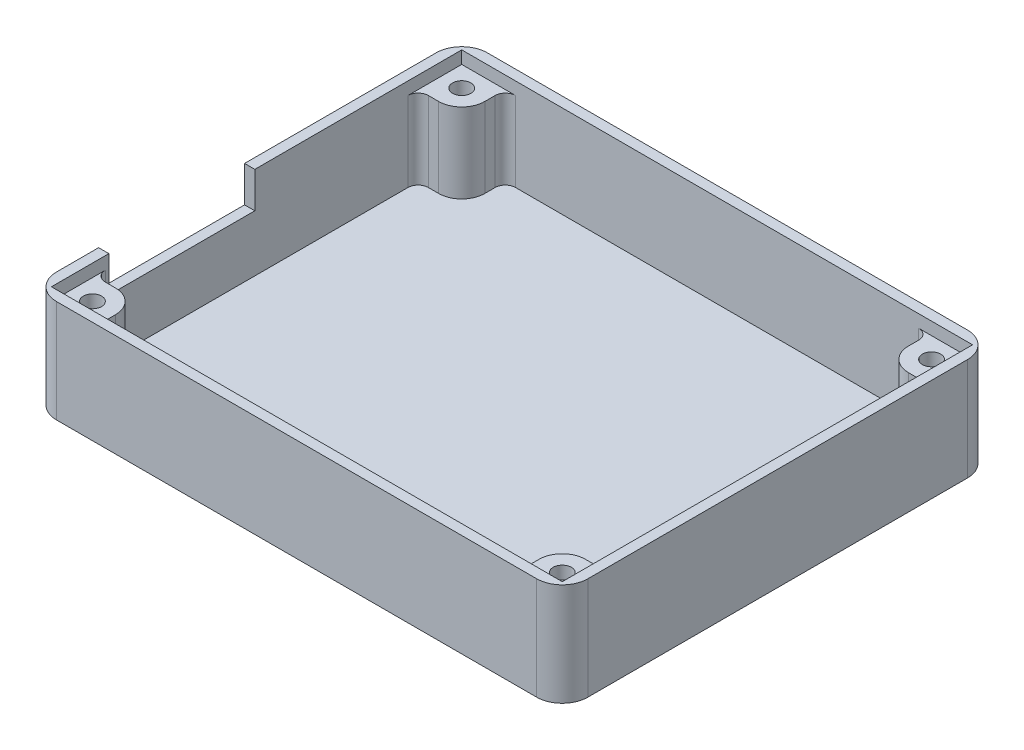
from build123d import *

# Parameters (mm, degrees)
SKETCH5_W             = 65.786
SKETCH5_H             = 53.34
BOSS_EXTRUDE1_DEPTH   = 12.7
CUT_EXTRUDE1_DEPTH    = 11.43
FILLET1_R             = 3.175
SKETCH8_W             = 63.246
SKETCH8_H             = 50.8
CUT_EXTRUDE2_DEPTH    = 1.5621
SKETCH9_W             = 15.301638829
SKETCH9_H             = 18.07026672
CUT_EXTRUDE3_DEPTH    = 4.445
BODY_MOVE_COPY1_ANGLE = 180


with BuildPart() as part:
    # Sketch5 → Boss-Extrude1 (new body)
    with BuildSketch(Plane(origin=(0, 0, 0), x_dir=(1, 0, 0), z_dir=(0, 1, 0))):
        with Locations((-7.078072202, 8.960606498)):
            Rectangle(SKETCH5_W, SKETCH5_H)
    extrude(amount=BOSS_EXTRUDE1_DEPTH)

    # Sketch7 → Cut-Extrude1 (cut)
    with BuildSketch(Plane.XZ):
        with BuildLine():
            Line((-32.033572202, -34.360606498), (17.877427798, -34.360606498))
            ThreePointArc((17.877427798, -34.360606498), (18.77545341, -33.98863211), (19.147427798, -33.090606498))
            Line((19.147427798, -33.090606498), (19.147427798, -31.820606498))
            ThreePointArc((19.147427798, -31.820606498), (19.984370171, -29.800048871), (22.004927798, -28.963106498))
            Line((22.004927798, -28.963106498), (23.274927798, -28.963106498))
            ThreePointArc((23.274927798, -28.963106498), (24.17295341, -28.59113211), (24.544927798, -27.693106498))
            Line((24.544927798, -27.693106498), (24.544927798, 9.771893502))
            ThreePointArc((24.544927798, 9.771893502), (24.17295341, 10.669919114), (23.274927798, 11.041893502))
            Line((23.274927798, 11.041893502), (22.004927798, 11.041893502))
            ThreePointArc((22.004927798, 11.041893502), (19.984370171, 11.878835875), (19.147427798, 13.899393502))
            Line((19.147427798, 13.899393502), (19.147427798, 15.169393502))
            ThreePointArc((19.147427798, 15.169393502), (18.77545341, 16.067419114), (17.877427798, 16.439393502))
            Line((17.877427798, 16.439393502), (-32.033572202, 16.439393502))
            ThreePointArc((-32.033572202, 16.439393502), (-32.931597814, 16.067419114), (-33.303572202, 15.169393502))
            Line((-33.303572202, 15.169393502), (-33.303572202, 13.899393502))
            ThreePointArc((-33.303572202, 13.899393502), (-34.140514575, 11.878835875), (-36.161072202, 11.041893502))
            Line((-36.161072202, 11.041893502), (-37.431072202, 11.041893502))
            ThreePointArc((-37.431072202, 11.041893502), (-38.329097814, 10.669919114), (-38.701072202, 9.771893502))
            Line((-38.701072202, 9.771893502), (-38.701072202, -27.693106498))
            ThreePointArc((-38.701072202, -27.693106498), (-38.329097814, -28.59113211), (-37.431072202, -28.963106498))
            Line((-37.431072202, -28.963106498), (-36.161072202, -28.963106498))
            ThreePointArc((-36.161072202, -28.963106498), (-34.140514575, -29.800048871), (-33.303572202, -31.820606498))
            Line((-33.303572202, -31.820606498), (-33.303572202, -33.090606498))
            ThreePointArc((-33.303572202, -33.090606498), (-32.931597814, -33.98863211), (-32.033572202, -34.360606498))
        make_face()
    extrude(amount=-CUT_EXTRUDE1_DEPTH, mode=Mode.SUBTRACT)

    # Fillet1
    fillet1_edges = [part.edges().sort_by_distance(p)[0] for p in [
        (-39.971072202, 6.35, 17.709393502),
        (-39.971072202, 6.35, -35.630606498),
        (25.814927798, 6.35, -35.630606498),
        (25.814927798, 6.35, 17.709393502),
    ]]
    fillet(fillet1_edges, radius=FILLET1_R)

    # Sketch8 → Cut-Extrude2 (cut)
    with BuildSketch(Plane(origin=(0, 0, 0), x_dir=(1, 0, 0), z_dir=(0, 1, 0))):
        with Locations((-7.078072202, 8.960606498)):
            Rectangle(SKETCH8_W, SKETCH8_H)
    extrude(amount=CUT_EXTRUDE2_DEPTH, mode=Mode.SUBTRACT)

    # Sketch9 → Cut-Extrude3 (cut)
    with BuildSketch(Plane(origin=(0, 0, 0), x_dir=(1, 0, 0), z_dir=(0, 1, 0))):
        with Locations((26.561690875, -0.292260142)):
            Rectangle(SKETCH9_W, SKETCH9_H)
    extrude(amount=CUT_EXTRUDE3_DEPTH, mode=Mode.SUBTRACT)

    # Sketch10 → Tap Drill for #4-40 Tap1 (revolve, cut)
    with BuildSketch(Plane(origin=(-36.161072202, 0, 13.899393502), x_dir=(0, 0, -1), z_dir=(1, 0, 0))):
        Polygon((0, 0), (0, 9.569152758), (1.1303, 8.89), (1.1303, 0), align=None)
    tap_drill_for_4_40_tap1 = revolve(axis=Axis((-36.161072202, -6.35, 13.899393502), (0, 1, 0)), mode=Mode.SUBTRACT)

    # Mirror1: Tap Drill for #4-40 Tap1 across plane
    add(tap_drill_for_4_40_tap1.mirror(Plane(origin=(-7.078072202, 0, 0), x_dir=(0, 0, 1), z_dir=(1, 0, 0))), mode=Mode.SUBTRACT)

    # Mirror2: Tap Drill for #4-40 Tap1 across plane
    add(tap_drill_for_4_40_tap1.mirror(Plane.XY.offset(-8.960606498)), mode=Mode.SUBTRACT)

    # Mirror2 copy 1 sketch → Mirror2 copy 1 (revolve, cut)
    with BuildSketch(Plane(origin=(22.004927798, 0, -31.820606498), x_dir=(0, 0, 1), z_dir=(-1, 0, 0))):
        Polygon((0, 0), (0, 9.569152758), (1.1303, 8.89), (1.1303, 0), align=None)
    revolve(axis=Axis((22.004927798, -6.35, -31.820606498), (0, 1, 0)), mode=Mode.SUBTRACT)


with BuildPart() as part_1:
    # Body-Move/Copy1: moved
    add(part.part.rotate(Axis((-7.078072202, 6.35, 0), (0, 0, 1)), BODY_MOVE_COPY1_ANGLE))


solid = part_1.part
